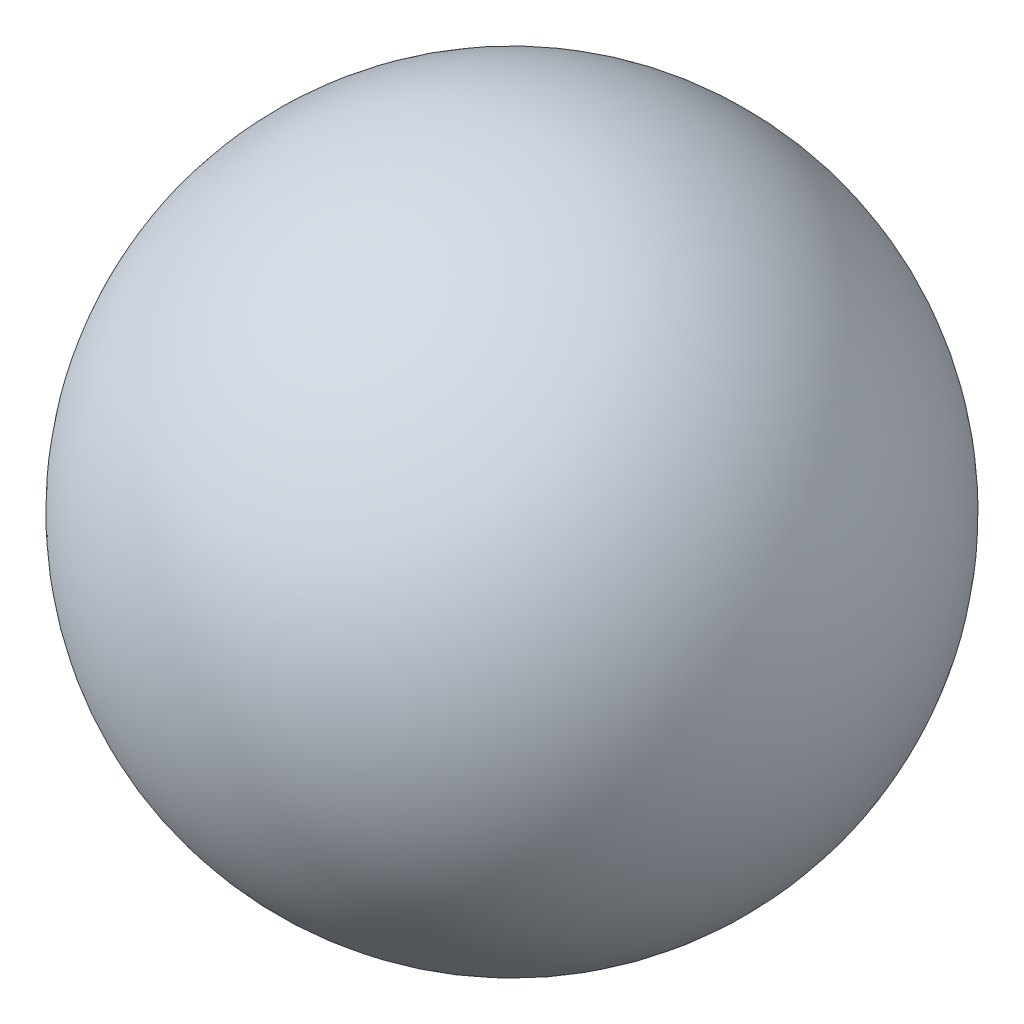
from build123d import *


with BuildPart() as part:
    # Croquis1 → Revolución1 (revolve)
    with BuildSketch(Plane.XY):
        with BuildLine():
            Line((-33.6378695, -23.505957272), (16.3621305, -23.505957272))
            ThreePointArc((16.3621305, -23.505957272), (-8.6378695, 1.494042728), (-33.6378695, -23.505957272))
        make_face()
    revolve(axis=Axis((-33.6378695, -23.505957272, 0), (1, 0, 0)))


solid = part.part
